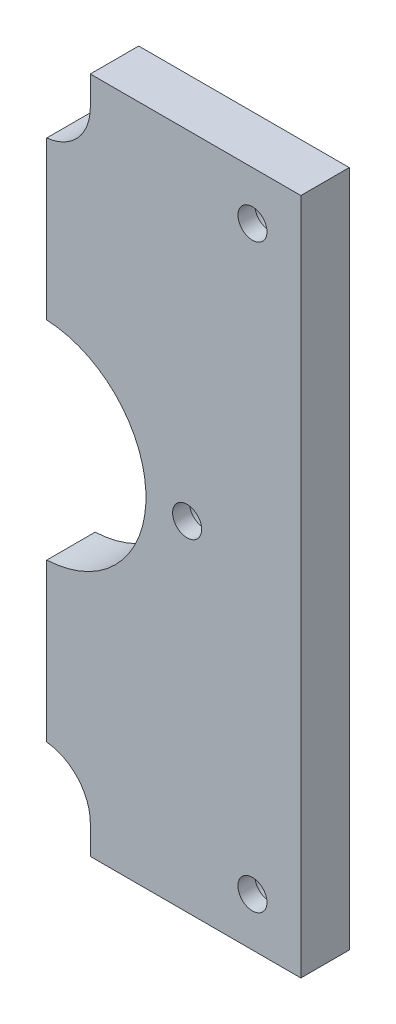
from build123d import *

# Parameters (mm, degrees)
SKETCH1_R          = 3
EXTRUDE2_DEPTH     = 10
SKETCH5_R          = 5
CUT_EXTRUDE2_DEPTH = 6.5
SKETCH7_R          = 2.25
CUT_EXTRUDE3_DEPTH = 20
SKETCH8_R          = 4
CUT_EXTRUDE4_DEPTH = 10


with BuildPart() as part:
    # Sketch1 → Extrude2 (new body)
    with BuildSketch(Plane.XY):
        with BuildLine():
            ThreePointArc((46.5, 134), (43.916178451, 127.291773917), (37.499940564, 124.050119656))
            Line((37.499940564, 124.050119656), (37.499940564, 100))
            Line((37.499940564, 100), (37.499940564, 91.476734362))
            ThreePointArc((37.499940564, 91.476734362), (58, 70), (37.499940564, 48.523265638))
            Line((37.499940564, 48.523265638), (37.499940564, 39.989097297))
            Line((37.499940564, 39.989097297), (37.499940564, 15.949880344))
            ThreePointArc((37.499940564, 15.949880344), (43.916178451, 12.708226083), (46.5, 6))
            Line((46.5, 6), (46.5, 0))
            Line((46.5, 0), (90, 0))
            Line((90, 0), (90, 140))
            Line((90, 140), (46.5, 140))
            Line((46.5, 140), (46.5, 134))
        make_face()
        with Locations((80, 10)):
            Circle(SKETCH1_R, mode=Mode.SUBTRACT)
        with Locations((66.5, 70)):
            Circle(SKETCH1_R, mode=Mode.SUBTRACT)
        with Locations((80, 130)):
            Circle(SKETCH1_R, mode=Mode.SUBTRACT)
    extrude(amount=EXTRUDE2_DEPTH)

    # Sketch5 → Cut-Extrude2 (cut)
    with BuildSketch(Plane(origin=(0, 0, 0), x_dir=(-1, 0, 0), z_dir=(0, 0, -1))):
        with Locations((-66.5, 70)):
            Circle(SKETCH5_R)
        with Locations((-80, 10)):
            Circle(SKETCH5_R)
        with Locations((-80, 130)):
            Circle(SKETCH5_R)
    extrude(amount=-CUT_EXTRUDE2_DEPTH, mode=Mode.SUBTRACT)

    # Sketch7 → Cut-Extrude3 (cut)
    with BuildSketch(Plane.ZY.offset(-37.499940564)):
        with Locations((5, 110)):
            Circle(SKETCH7_R)
        with Locations((5, 30)):
            Circle(SKETCH7_R)
    extrude(amount=-CUT_EXTRUDE3_DEPTH, mode=Mode.SUBTRACT)

    # Sketch8 → Cut-Extrude4 (cut)
    with BuildSketch(Plane.ZY.offset(-37.499940564)):
        with Locations((5, 41.023265638)):
            Circle(SKETCH8_R)
        with Locations((5, 98.976734362)):
            Circle(SKETCH8_R)
    extrude(amount=-CUT_EXTRUDE4_DEPTH, mode=Mode.SUBTRACT)


solid = part.part
